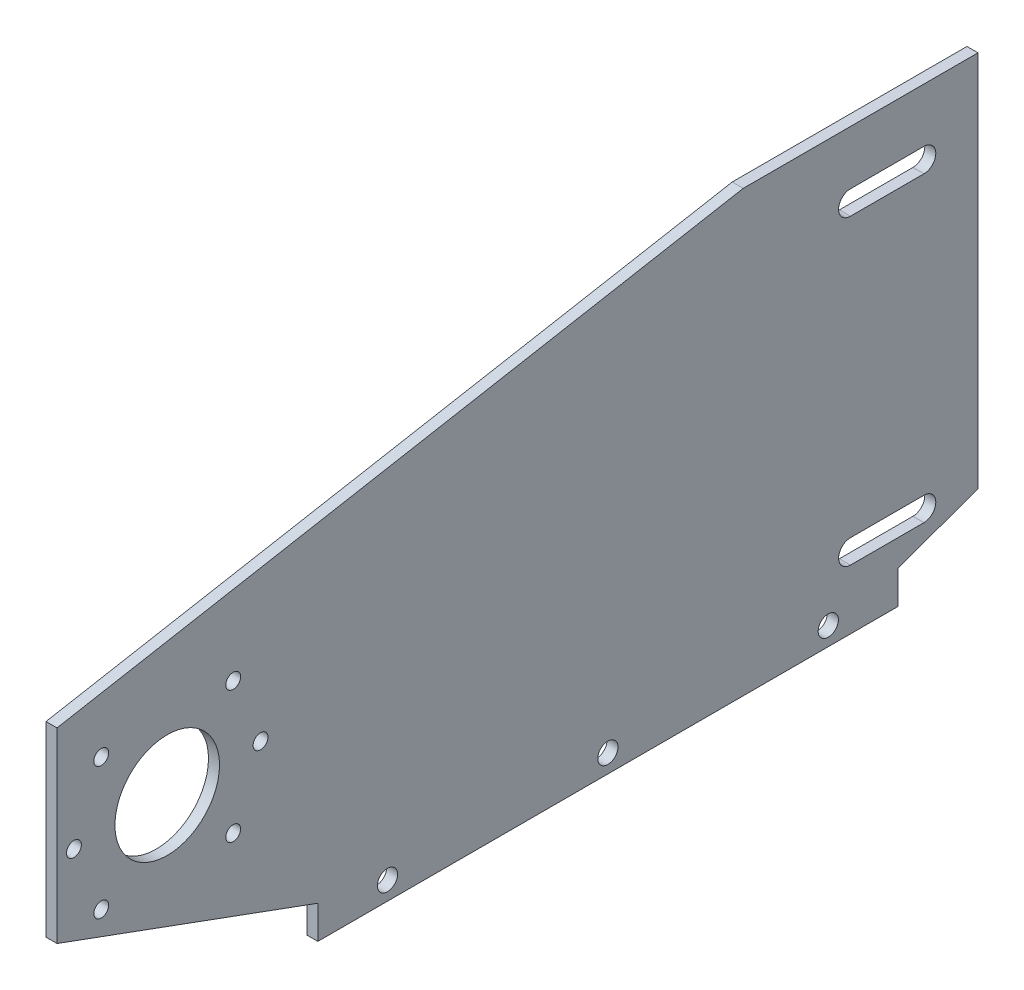
from build123d import *

# Parameters (mm, degrees)
SKETCH1_W           = 300
SKETCH1_H           = 150
SKETCH1_R           = 14.235
BOSS_EXTRUDE1_DEPTH = 3
CUT_EXTRUDE1_REACH  = 5
SKETCH2_R           = 3.225
SKETCH4_R           = 2.0193
CUT_EXTRUDE4_DEPTH  = 4
CUT_EXTRUDE5_DEPTH  = 4
CUT_EXTRUDE6_DEPTH  = 10
SKETCH7_R           = 2.75
CUT_EXTRUDE7_DEPTH  = 4


with BuildPart() as part:
    # Sketch1 → Boss-Extrude1 (new body)
    with BuildSketch(Plane(origin=(0, 0, 0), x_dir=(0, 0, -1), z_dir=(1, 0, 0))):
        with Locations((150, 75)):
            Rectangle(SKETCH1_W, SKETCH1_H)
        with Locations((30, 55)):
            Circle(SKETCH1_R, mode=Mode.SUBTRACT)
    extrude(amount=BOSS_EXTRUDE1_DEPTH)

    # Sketch2 → Cut-Extrude1 (cut, up to next)
    with BuildSketch(Plane.ZY, mode=Mode.PRIVATE) as cut_extrude1_sk1:
        with Locations((-10, 110)):
            Circle(SKETCH2_R)
    cut_extrude1_tool1 = extrude(cut_extrude1_sk1.sketch, amount=-CUT_EXTRUDE1_REACH, mode=Mode.PRIVATE) & part.part
    add(cut_extrude1_tool1.solids().sort_by_distance((0, 110, -10))[0], mode=Mode.SUBTRACT)
    # Sketch2 → Cut-Extrude1 (cut, up to next)
    with BuildSketch(Plane.ZY, mode=Mode.PRIVATE) as cut_extrude1_sk2:
        with BuildLine():
            Line((-236, 104.938413591), (-216, 104.938413591))
            ThreePointArc((-216, 104.938413591), (-212.77, 101.708413591), (-216, 98.478413591))
            Line((-216, 98.478413591), (-236, 98.478413591))
            ThreePointArc((-236, 98.478413591), (-239.23, 101.708413591), (-236, 104.938413591))
        make_face()
    cut_extrude1_tool2 = extrude(cut_extrude1_sk2.sketch, amount=-CUT_EXTRUDE1_REACH, mode=Mode.PRIVATE) & part.part
    add(cut_extrude1_tool2.solids().sort_by_distance((0, 101.708414, -226))[0], mode=Mode.SUBTRACT)
    # Sketch2 → Cut-Extrude1 (cut, up to next)
    with BuildSketch(Plane.ZY, mode=Mode.PRIVATE) as cut_extrude1_sk3:
        with BuildLine():
            Line((-216, 16.231694356), (-236, 16.231694356))
            ThreePointArc((-236, 16.231694356), (-239.225, 19.456694356), (-236, 22.681694356))
            Line((-236, 22.681694356), (-216, 22.681694356))
            ThreePointArc((-216, 22.681694356), (-212.775, 19.456694356), (-216, 16.231694356))
        make_face()
    cut_extrude1_tool3 = extrude(cut_extrude1_sk3.sketch, amount=-CUT_EXTRUDE1_REACH, mode=Mode.PRIVATE) & part.part
    add(cut_extrude1_tool3.solids().sort_by_distance((0, 19.456694, -226))[0], mode=Mode.SUBTRACT)

    # Sketch4 → Cut-Extrude4 (cut, through all)
    with BuildSketch(Plane(origin=(3, 0, 0), x_dir=(0, 0, -1), z_dir=(1, 0, 0))):
        with Locations((12.039487758, 37.039487758)):
            Circle(SKETCH4_R)
        with Locations((12.039487758, 72.960512242)):
            Circle(SKETCH4_R)
        with Locations((4.6, 55)):
            Circle(SKETCH4_R)
        with Locations((47.960512242, 37.039487758)):
            Circle(SKETCH4_R)
        with Locations((55.4, 55)):
            Circle(SKETCH4_R)
        with Locations((47.960512242, 72.960512242)):
            Circle(SKETCH4_R)
    extrude(amount=-CUT_EXTRUDE4_DEPTH, mode=Mode.SUBTRACT)

    # Sketch5 → Cut-Extrude5 (cut, through all)
    with BuildSketch(Plane.ZY):
        Polygon((-71, 0), (-71, 9), (0, 35), (0, 0), align=None)
        Polygon((0, 85.848631797), (-186.802640374, 119.641480316), (-300.310491503, 119.641480316), (-300.310491503, 150), (0, 150), align=None)
    extrude(amount=-CUT_EXTRUDE5_DEPTH, mode=Mode.SUBTRACT)

    # Sketch6 → Cut-Extrude6 (cut)
    with BuildSketch(Plane.ZY):
        Polygon((-250.717958721, 165.712896148), (-250.717958721, 16.875947155), (-228.92403237, 9), (-228.92403237, 0), (-355.768886916, 0), (-364.830865455, 165.712896148), align=None)
    extrude(amount=-CUT_EXTRUDE6_DEPTH, mode=Mode.SUBTRACT)

    # Sketch7 → Cut-Extrude7 (cut, through all)
    with BuildSketch(Plane(origin=(3, 0, 0), x_dir=(0, 0, -1), z_dir=(1, 0, 0))):
        with Locations((89.962016185, 5)):
            Circle(SKETCH7_R)
        with Locations((149.962016185, 5)):
            Circle(SKETCH7_R)
        with Locations((209.962016185, 5)):
            Circle(SKETCH7_R)
    extrude(amount=-CUT_EXTRUDE7_DEPTH, mode=Mode.SUBTRACT)


solid = part.part
